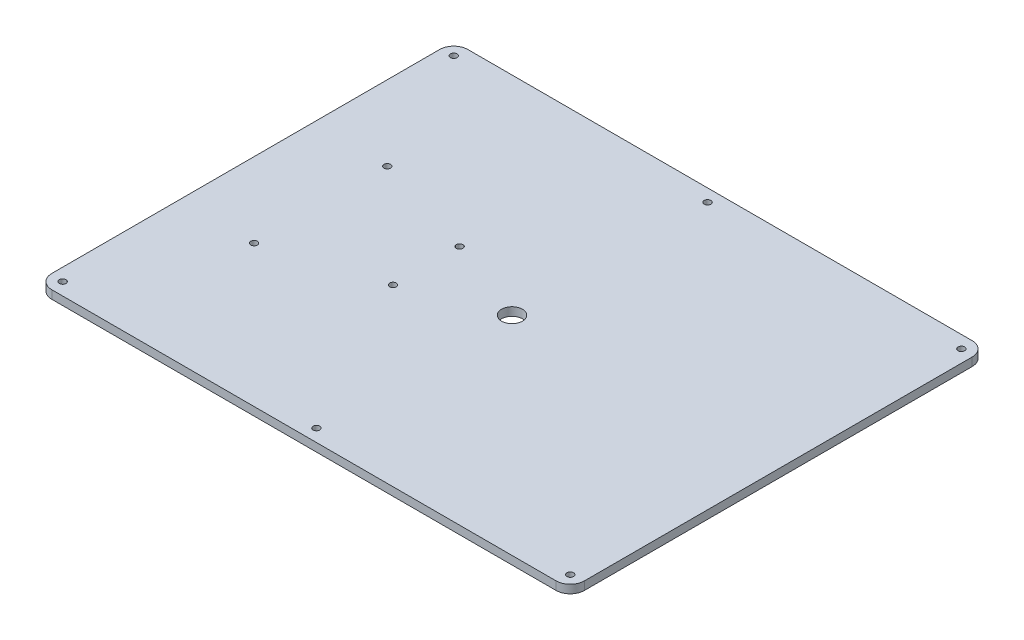
from build123d import *

# Parameters (mm, degrees)
CROQUIS1_R              = 4
SALIENTE_EXTRUIR1_DEPTH = 10
CROQUIS2_R              = 4
CROQUIS2_R_2            = 12.5
CORTAR_EXTRUIR1_DEPTH   = 10


with BuildPart() as part:
    # Croquis1 → Saliente-Extruir1 (new body)
    with BuildSketch(Plane(origin=(0, 0, 0), x_dir=(1, 0, 0), z_dir=(0, 1, 0))):
        with BuildLine():
            Line((-303, 250), (303, 250))
            ThreePointArc((303, 250), (315.02081528, 245.02081528), (320, 233))
            Line((320, 233), (320, -233))
            ThreePointArc((320, -233), (315.02081528, -245.02081528), (303, -250))
            Line((303, -250), (-303, -250))
            ThreePointArc((-303, -250), (-315.02081528, -245.02081528), (-320, -233))
            Line((-320, -233), (-320, 233))
            ThreePointArc((-320, 233), (-315.02081528, 245.02081528), (-303, 250))
        make_face()
        with Locations((0, 235)):
            Circle(CROQUIS1_R, mode=Mode.SUBTRACT)
        with Locations((305, 235)):
            Circle(CROQUIS1_R, mode=Mode.SUBTRACT)
        with Locations((-305, 235)):
            Circle(CROQUIS1_R, mode=Mode.SUBTRACT)
        with Locations((0, -235)):
            Circle(CROQUIS1_R, mode=Mode.SUBTRACT)
        with Locations((305, -235)):
            Circle(CROQUIS1_R, mode=Mode.SUBTRACT)
        with Locations((-305, -235)):
            Circle(CROQUIS1_R, mode=Mode.SUBTRACT)
    extrude(amount=SALIENTE_EXTRUIR1_DEPTH)

    # Croquis2 → Cortar-Extruir1 (cut)
    with BuildSketch(Plane(origin=(0, 10, 0), x_dir=(1, 0, 0), z_dir=(0, 1, 0))):
        with Locations((-230, 80)):
            Circle(CROQUIS2_R)
        with Locations((-103, 40)):
            Circle(CROQUIS2_R)
        Circle(CROQUIS2_R_2)
        with Locations((-103, -40)):
            Circle(CROQUIS2_R)
        with Locations((-230, -80)):
            Circle(CROQUIS2_R)
    extrude(amount=-CORTAR_EXTRUIR1_DEPTH, mode=Mode.SUBTRACT)


solid = part.part
